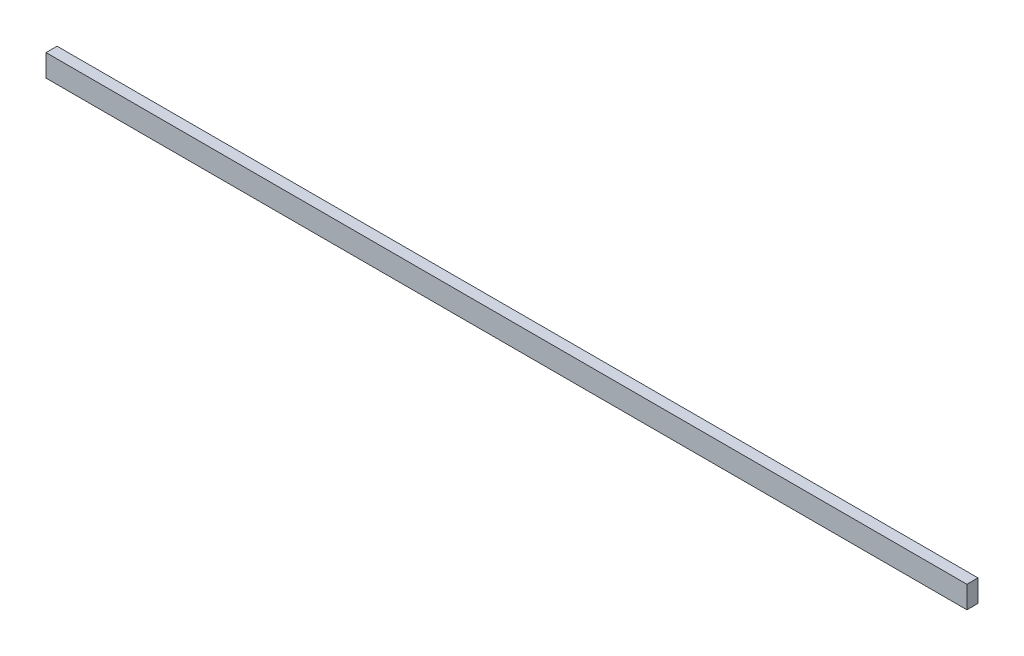
from build123d import *

# Parameters (mm, degrees)
SKETCH1_W           = 416
SKETCH1_H           = 10
BOSS_EXTRUDE1_DEPTH = 5


with BuildPart() as part:
    # Sketch1 → Boss-Extrude1 (new body)
    with BuildSketch(Plane.XY):
        Rectangle(SKETCH1_W, SKETCH1_H)
    extrude(amount=BOSS_EXTRUDE1_DEPTH)


solid = part.part
